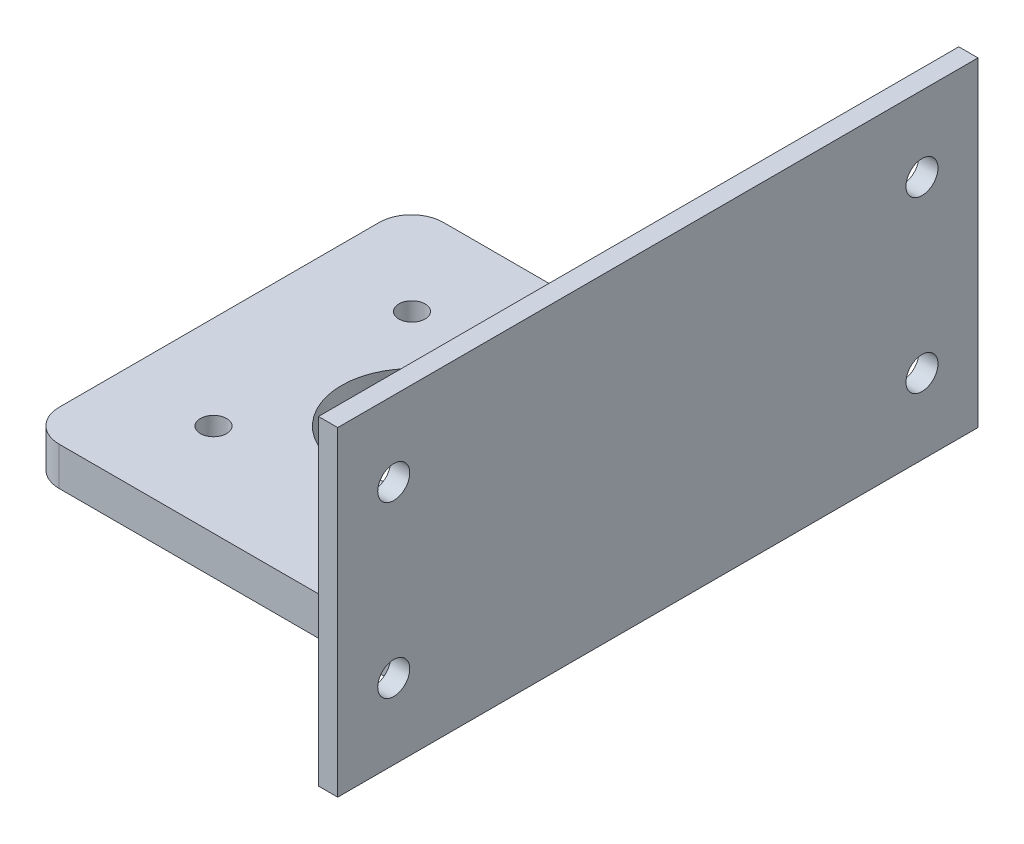
from build123d import *

# Parameters (mm, degrees)
EXTRUDE_1_DEPTH     = 60
SKETCH_4_R          = 11
SKETCH_4_R_2        = 2.05
CUT_EXTRUDE_3_DEPTH = 7
FILLET_2_R          = 5
SKETCH_5_W          = 100
SKETCH_5_H          = 50
SKETCH_5_R          = 2.5
EXTRUDE_2_DEPTH     = 3


with BuildPart() as part:
    # 草图1 → 凸台-拉伸1 (new body)
    with BuildSketch(Plane.XY):
        Polygon((0, 0), (68.5, 0), (68.5, 50), (65.5, 50), (65.5, 7), (64.5, 6), (0, 6), align=None)
    extrude(amount=EXTRUDE_1_DEPTH)

    # 草图4 → 切除-拉伸3 (cut, through all)
    with BuildSketch(Plane(origin=(0, 6, 0), x_dir=(1, 0, 0), z_dir=(0, 1, 0))):
        with Locations((30.1, -30)):
            Circle(SKETCH_4_R)
        with Locations((14.6, -14.5)):
            Circle(SKETCH_4_R_2)
        with Locations((45.6, -14.5)):
            Circle(SKETCH_4_R_2)
        with Locations((45.6, -45.5)):
            Circle(SKETCH_4_R_2)
        with Locations((14.6, -45.5)):
            Circle(SKETCH_4_R_2)
    extrude(amount=-CUT_EXTRUDE_3_DEPTH, mode=Mode.SUBTRACT)

    # 圆角2
    fillet_2_edges = [part.edges().sort_by_distance(p)[0] for p in [
        (0, 3, 0),
        (0, 3, 60),
    ]]
    fillet(fillet_2_edges, radius=FILLET_2_R)

    # 草图5 → 凸台-拉伸2 (add)
    with BuildSketch(Plane.ZY.offset(-65.5)):
        with Locations((30, 25)):
            Rectangle(SKETCH_5_W, SKETCH_5_H)
        with Locations((71.25, 11.75)):
            Circle(SKETCH_5_R, mode=Mode.SUBTRACT)
        with Locations((-11.25, 11.75)):
            Circle(SKETCH_5_R, mode=Mode.SUBTRACT)
        with Locations((-11.25, 38.25)):
            Circle(SKETCH_5_R, mode=Mode.SUBTRACT)
        with Locations((71.25, 38.25)):
            Circle(SKETCH_5_R, mode=Mode.SUBTRACT)
    extrude(amount=-EXTRUDE_2_DEPTH)


solid = part.part
